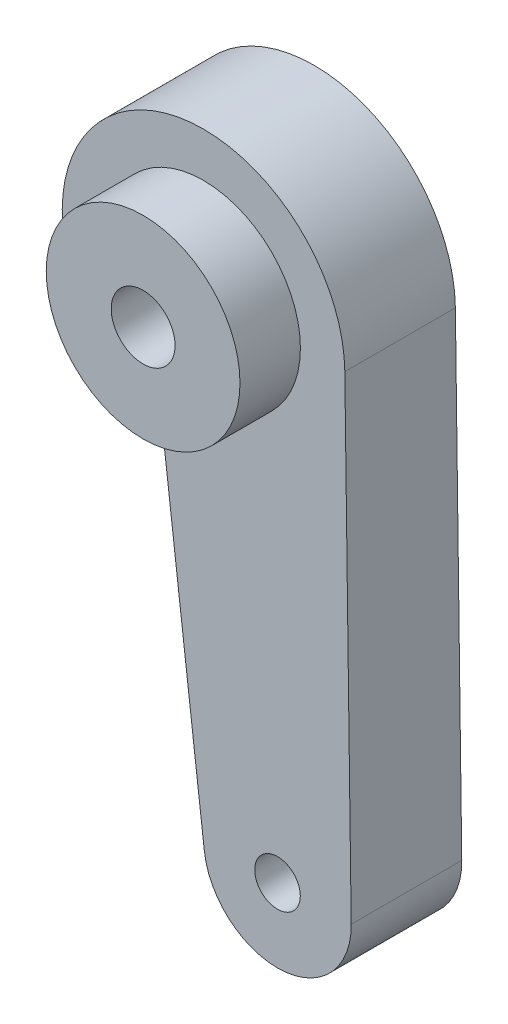
from build123d import *

# Parameters (mm, degrees)
ESBO_O1_R                = 2
ESBO_O1_R_2              = 5.5
RESSALTO_EXTRUS_O1_DEPTH = 9.7
ESBO_O2_R                = 8.5
ESBO_O2_R_2              = 2.8
RESSALTO_EXTRUS_O2_DEPTH = 5.3


with BuildPart() as part:
    # Esboço1 → Ressalto-extrusão1 (new body)
    with BuildSketch(Plane.XY):
        with BuildLine():
            Line((-3.631457669, -11.855371335), (0.071926714, -42.412329846))
            ThreePointArc((0.071926714, -42.412329846), (6.924703408, -48.086484209), (12.957802317, -41.547501589))
            Line((12.957802317, -41.547501589), (12.397968723, 0.166390596))
            ThreePointArc((12.397968723, 0.166390596), (-7.439329204, 9.919359621), (-3.631457669, -11.855371335))
        make_face()
        with Locations((6.491667521, -41.634282258)):
            Circle(ESBO_O1_R, mode=Mode.SUBTRACT)
        Circle(ESBO_O1_R_2, mode=Mode.SUBTRACT)
    extrude(amount=RESSALTO_EXTRUS_O1_DEPTH)

    # Esboço2 → Ressalto-extrusão2 (add)
    with BuildSketch(Plane.XY.offset(9.7)):
        Circle(ESBO_O2_R)
        Circle(ESBO_O2_R_2, mode=Mode.SUBTRACT)
    extrude(amount=RESSALTO_EXTRUS_O2_DEPTH)


solid = part.part
